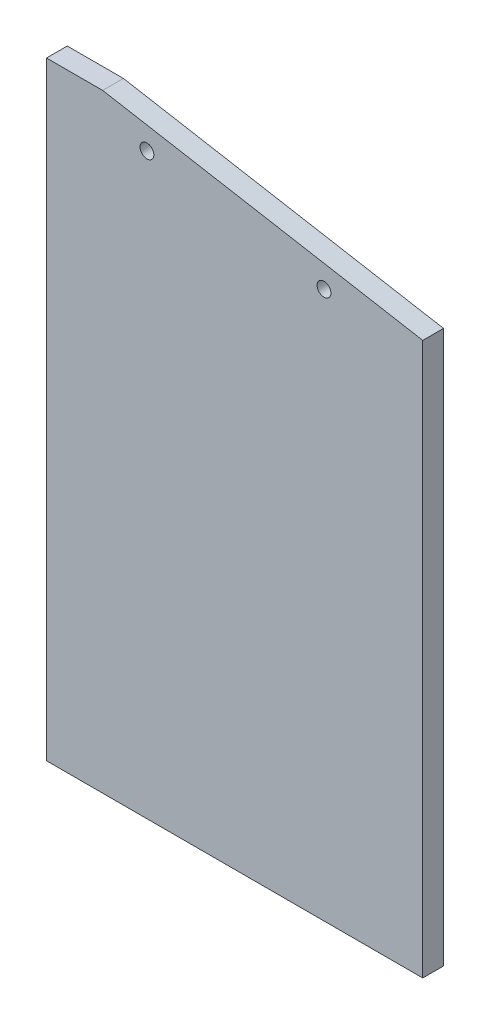
from build123d import *

# Parameters (mm, degrees)
BOSS_EXTRUDE1_DEPTH            = 11.90625
F_5_16_0_3125_DIAMETER_HOLE1_D = 7.9375
SKETCH4_W                      = 220.489922176
SKETCH4_H                      = 247.65
CUT_EXTRUDE1_DEPTH             = 12.90625


with BuildPart() as part:
    # Sketch1 → Boss-Extrude1 (new body)
    with BuildSketch(Plane.XY):
        Polygon((151.023557582, 150.952887465), (-32.640904146, 183.337887465), (-64.876442418, 183.337887465), (-64.876442418, -413.562112535), (-32.640904146, -413.562112535), (151.023557582, -381.177112535), align=None)
    extrude(amount=BOSS_EXTRUDE1_DEPTH)

    # 5/16 (0.3125) Diameter Hole1 (through all)
    with Locations(Plane.XY.offset(11.90625)):
        with Locations((94.359095854, 148.048442944), (-7.240904146, 165.963264184), (-7.240904146, -396.187489254), (94.359095854, -378.272668014)):
            Hole(F_5_16_0_3125_DIAMETER_HOLE1_D / 2)

    # Sketch4 → Cut-Extrude1 (cut, through all)
    with BuildSketch(Plane(origin=(0, 0, 0), x_dir=(-1, 0, 0), z_dir=(0, 0, -1))):
        with Locations((-45.36851867, -289.737112535)):
            Rectangle(SKETCH4_W, SKETCH4_H)
    extrude(amount=-CUT_EXTRUDE1_DEPTH, mode=Mode.SUBTRACT)


solid = part.part
